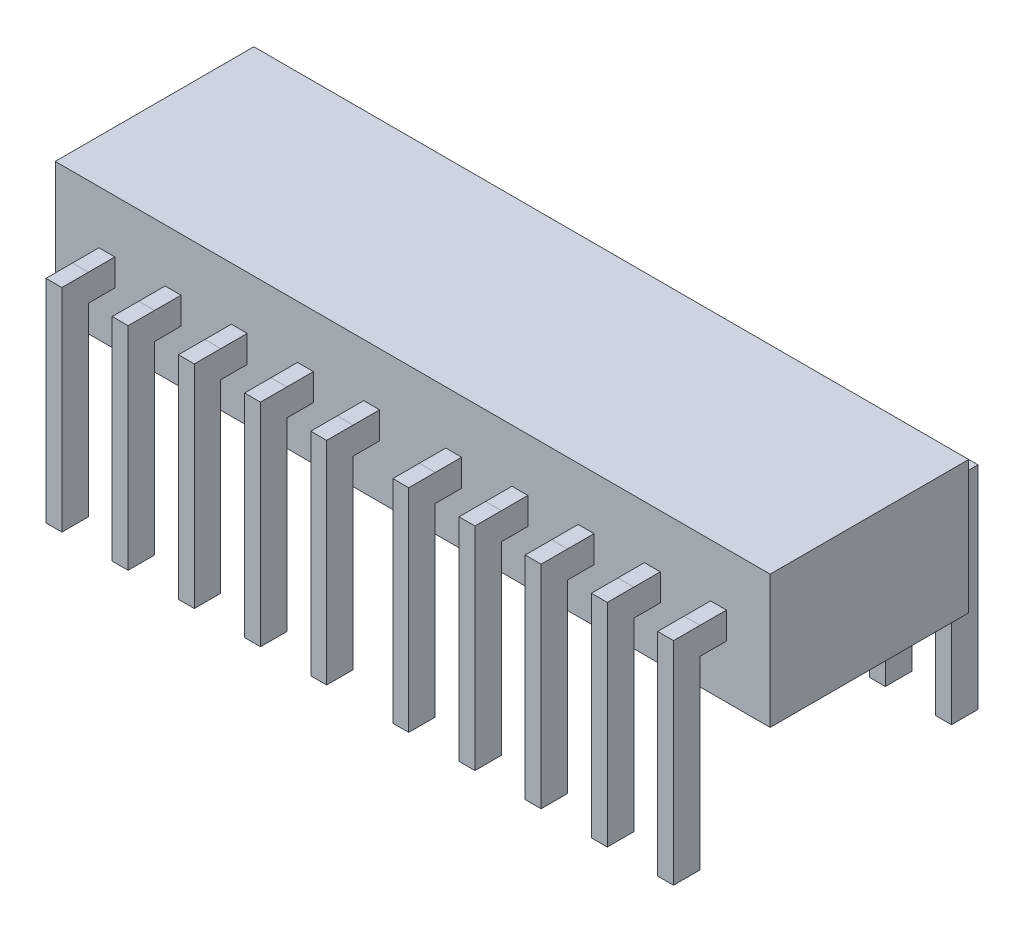
from build123d import *

# Parameters (mm, degrees)
BOSS_EXTRUDE3_DEPTH         = 2507.5
BOSS_EXTRUDE6_DEPTH         = 508
BOSS_EXTRUDE6_DEPTH_BACK    = 7494
SKETCH1_14_W                = 600
SKETCH1_14_H                = 1000
BOSS_EXTRUDE6_2_DEPTH       = 508
BOSS_EXTRUDE6_2_DEPTH_BACK  = 7494
BOSS_EXTRUDE6_3_DEPTH       = 508
BOSS_EXTRUDE6_3_DEPTH_BACK  = 7494
BOSS_EXTRUDE6_4_DEPTH       = 508
BOSS_EXTRUDE6_4_DEPTH_BACK  = 7494
BOSS_EXTRUDE6_5_DEPTH       = 508
BOSS_EXTRUDE6_5_DEPTH_BACK  = 7494
BOSS_EXTRUDE6_6_DEPTH       = 508
BOSS_EXTRUDE6_6_DEPTH_BACK  = 7494
BOSS_EXTRUDE6_7_DEPTH       = 508
BOSS_EXTRUDE6_7_DEPTH_BACK  = 7494
BOSS_EXTRUDE6_8_DEPTH       = 508
BOSS_EXTRUDE6_8_DEPTH_BACK  = 7494
BOSS_EXTRUDE6_9_DEPTH       = 508
BOSS_EXTRUDE6_9_DEPTH_BACK  = 7494
BOSS_EXTRUDE6_10_DEPTH      = 508
BOSS_EXTRUDE6_10_DEPTH_BACK = 7494
BOSS_EXTRUDE6_11_DEPTH      = 508
BOSS_EXTRUDE6_11_DEPTH_BACK = 7494
BOSS_EXTRUDE6_12_DEPTH      = 508
BOSS_EXTRUDE6_12_DEPTH_BACK = 7494
BOSS_EXTRUDE6_13_DEPTH      = 508
BOSS_EXTRUDE6_13_DEPTH_BACK = 7494
BOSS_EXTRUDE6_14_DEPTH      = 508
BOSS_EXTRUDE6_14_DEPTH_BACK = 7494
BOSS_EXTRUDE6_15_DEPTH      = 508
BOSS_EXTRUDE6_15_DEPTH_BACK = 7494
BOSS_EXTRUDE6_16_DEPTH      = 508
BOSS_EXTRUDE6_16_DEPTH_BACK = 7494
BOSS_EXTRUDE6_17_DEPTH      = 508
BOSS_EXTRUDE6_17_DEPTH_BACK = 7494
BOSS_EXTRUDE6_18_DEPTH      = 508
BOSS_EXTRUDE6_18_DEPTH_BACK = 7494
BOSS_EXTRUDE6_19_DEPTH      = 508
BOSS_EXTRUDE6_19_DEPTH_BACK = 7494
BOSS_EXTRUDE6_20_DEPTH      = 508
BOSS_EXTRUDE6_20_DEPTH_BACK = 7494
SKETCH1_17_W                = 600
SKETCH1_17_H                = 1000
BOSS_EXTRUDE8_DEPTH         = 507.5


with BuildPart() as part:
    # Sketch1 → Boss-Extrude3 (new, symmetric)
    with BuildSketch(Plane(origin=(0, 0, 0), x_dir=(1, 0, 0), z_dir=(0, 1, 0))):
        Polygon((-13500, 3750), (-13500, -3750), (-11850, -3750), (-11250, -3750), (-9350, -3750), (-8750, -3750), (-6850, -3750), (-6250, -3750), (-4350, -3750), (-3750, -3750), (-1850, -3750), (-1250, -3750), (1250, -3750), (1850, -3750), (3750, -3750), (4350, -3750), (6250, -3750), (6850, -3750), (8750, -3750), (9350, -3750), (11250, -3750), (11850, -3750), (13500, -3750), (13500, 3750), (11850, 3750), (11250, 3750), (9350, 3750), (8750, 3750), (6850, 3750), (6250, 3750), (4350, 3750), (3750, 3750), (1850, 3750), (1250, 3750), (-1250, 3750), (-1850, 3750), (-3750, 3750), (-4350, 3750), (-6250, 3750), (-6850, 3750), (-8750, 3750), (-9350, 3750), (-11250, 3750), (-11850, 3750), align=None)
    extrude(amount=BOSS_EXTRUDE3_DEPTH, both=True)



with BuildPart() as body_2:
    # Sketch1_14 → Boss-Extrude6 (new, two sides: drawn at the far end of the back side and taken through both)
    with BuildSketch(Plane(origin=(0, 0, 0), x_dir=(1, 0, 0), z_dir=(0, 1, 0)).offset(-BOSS_EXTRUDE6_DEPTH_BACK)):
        with Locations((-11550, -5250)):
            Rectangle(SKETCH1_14_W, SKETCH1_14_H)
    extrude(amount=BOSS_EXTRUDE6_DEPTH + BOSS_EXTRUDE6_DEPTH_BACK)


with BuildPart() as body_3:
    # Sketch1_14 → Boss-Extrude6 2 (new, two sides: drawn at the far end of the back side and taken through both)
    with BuildSketch(Plane(origin=(0, 0, 0), x_dir=(1, 0, 0), z_dir=(0, 1, 0)).offset(-BOSS_EXTRUDE6_2_DEPTH_BACK)):
        with Locations((-11550, 5250)):
            Rectangle(SKETCH1_14_W, SKETCH1_14_H)
    extrude(amount=BOSS_EXTRUDE6_2_DEPTH + BOSS_EXTRUDE6_2_DEPTH_BACK)


with BuildPart() as body_4:
    # Sketch1_14 → Boss-Extrude6 3 (new, two sides: drawn at the far end of the back side and taken through both)
    with BuildSketch(Plane(origin=(0, 0, 0), x_dir=(1, 0, 0), z_dir=(0, 1, 0)).offset(-BOSS_EXTRUDE6_3_DEPTH_BACK)):
        with Locations((-9050, -5250)):
            Rectangle(SKETCH1_14_W, SKETCH1_14_H)
    extrude(amount=BOSS_EXTRUDE6_3_DEPTH + BOSS_EXTRUDE6_3_DEPTH_BACK)


with BuildPart() as body_5:
    # Sketch1_14 → Boss-Extrude6 4 (new, two sides: drawn at the far end of the back side and taken through both)
    with BuildSketch(Plane(origin=(0, 0, 0), x_dir=(1, 0, 0), z_dir=(0, 1, 0)).offset(-BOSS_EXTRUDE6_4_DEPTH_BACK)):
        with Locations((-9050, 5250)):
            Rectangle(SKETCH1_14_W, SKETCH1_14_H)
    extrude(amount=BOSS_EXTRUDE6_4_DEPTH + BOSS_EXTRUDE6_4_DEPTH_BACK)


with BuildPart() as body_6:
    # Sketch1_14 → Boss-Extrude6 5 (new, two sides: drawn at the far end of the back side and taken through both)
    with BuildSketch(Plane(origin=(0, 0, 0), x_dir=(1, 0, 0), z_dir=(0, 1, 0)).offset(-BOSS_EXTRUDE6_5_DEPTH_BACK)):
        with Locations((-6550, -5250)):
            Rectangle(SKETCH1_14_W, SKETCH1_14_H)
    extrude(amount=BOSS_EXTRUDE6_5_DEPTH + BOSS_EXTRUDE6_5_DEPTH_BACK)


with BuildPart() as body_7:
    # Sketch1_14 → Boss-Extrude6 6 (new, two sides: drawn at the far end of the back side and taken through both)
    with BuildSketch(Plane(origin=(0, 0, 0), x_dir=(1, 0, 0), z_dir=(0, 1, 0)).offset(-BOSS_EXTRUDE6_6_DEPTH_BACK)):
        with Locations((-6550, 5250)):
            Rectangle(SKETCH1_14_W, SKETCH1_14_H)
    extrude(amount=BOSS_EXTRUDE6_6_DEPTH + BOSS_EXTRUDE6_6_DEPTH_BACK)


with BuildPart() as body_8:
    # Sketch1_14 → Boss-Extrude6 7 (new, two sides: drawn at the far end of the back side and taken through both)
    with BuildSketch(Plane(origin=(0, 0, 0), x_dir=(1, 0, 0), z_dir=(0, 1, 0)).offset(-BOSS_EXTRUDE6_7_DEPTH_BACK)):
        with Locations((-4050, -5250)):
            Rectangle(SKETCH1_14_W, SKETCH1_14_H)
    extrude(amount=BOSS_EXTRUDE6_7_DEPTH + BOSS_EXTRUDE6_7_DEPTH_BACK)


with BuildPart() as body_9:
    # Sketch1_14 → Boss-Extrude6 8 (new, two sides: drawn at the far end of the back side and taken through both)
    with BuildSketch(Plane(origin=(0, 0, 0), x_dir=(1, 0, 0), z_dir=(0, 1, 0)).offset(-BOSS_EXTRUDE6_8_DEPTH_BACK)):
        with Locations((-4050, 5250)):
            Rectangle(SKETCH1_14_W, SKETCH1_14_H)
    extrude(amount=BOSS_EXTRUDE6_8_DEPTH + BOSS_EXTRUDE6_8_DEPTH_BACK)


with BuildPart() as body_10:
    # Sketch1_14 → Boss-Extrude6 9 (new, two sides: drawn at the far end of the back side and taken through both)
    with BuildSketch(Plane(origin=(0, 0, 0), x_dir=(1, 0, 0), z_dir=(0, 1, 0)).offset(-BOSS_EXTRUDE6_9_DEPTH_BACK)):
        with Locations((-1550, -5250)):
            Rectangle(SKETCH1_14_W, SKETCH1_14_H)
    extrude(amount=BOSS_EXTRUDE6_9_DEPTH + BOSS_EXTRUDE6_9_DEPTH_BACK)


with BuildPart() as body_11:
    # Sketch1_14 → Boss-Extrude6 10 (new, two sides: drawn at the far end of the back side and taken through both)
    with BuildSketch(Plane(origin=(0, 0, 0), x_dir=(1, 0, 0), z_dir=(0, 1, 0)).offset(-BOSS_EXTRUDE6_10_DEPTH_BACK)):
        with Locations((-1550, 5250)):
            Rectangle(SKETCH1_14_W, SKETCH1_14_H)
    extrude(amount=BOSS_EXTRUDE6_10_DEPTH + BOSS_EXTRUDE6_10_DEPTH_BACK)


with BuildPart() as body_12:
    # Sketch1_14 → Boss-Extrude6 11 (new, two sides: drawn at the far end of the back side and taken through both)
    with BuildSketch(Plane(origin=(0, 0, 0), x_dir=(1, 0, 0), z_dir=(0, 1, 0)).offset(-BOSS_EXTRUDE6_11_DEPTH_BACK)):
        with Locations((1550, -5250)):
            Rectangle(SKETCH1_14_W, SKETCH1_14_H)
    extrude(amount=BOSS_EXTRUDE6_11_DEPTH + BOSS_EXTRUDE6_11_DEPTH_BACK)


with BuildPart() as body_13:
    # Sketch1_14 → Boss-Extrude6 12 (new, two sides: drawn at the far end of the back side and taken through both)
    with BuildSketch(Plane(origin=(0, 0, 0), x_dir=(1, 0, 0), z_dir=(0, 1, 0)).offset(-BOSS_EXTRUDE6_12_DEPTH_BACK)):
        with Locations((1550, 5250)):
            Rectangle(SKETCH1_14_W, SKETCH1_14_H)
    extrude(amount=BOSS_EXTRUDE6_12_DEPTH + BOSS_EXTRUDE6_12_DEPTH_BACK)


with BuildPart() as body_14:
    # Sketch1_14 → Boss-Extrude6 13 (new, two sides: drawn at the far end of the back side and taken through both)
    with BuildSketch(Plane(origin=(0, 0, 0), x_dir=(1, 0, 0), z_dir=(0, 1, 0)).offset(-BOSS_EXTRUDE6_13_DEPTH_BACK)):
        with Locations((4050, -5250)):
            Rectangle(SKETCH1_14_W, SKETCH1_14_H)
    extrude(amount=BOSS_EXTRUDE6_13_DEPTH + BOSS_EXTRUDE6_13_DEPTH_BACK)


with BuildPart() as body_15:
    # Sketch1_14 → Boss-Extrude6 14 (new, two sides: drawn at the far end of the back side and taken through both)
    with BuildSketch(Plane(origin=(0, 0, 0), x_dir=(1, 0, 0), z_dir=(0, 1, 0)).offset(-BOSS_EXTRUDE6_14_DEPTH_BACK)):
        with Locations((4050, 5250)):
            Rectangle(SKETCH1_14_W, SKETCH1_14_H)
    extrude(amount=BOSS_EXTRUDE6_14_DEPTH + BOSS_EXTRUDE6_14_DEPTH_BACK)


with BuildPart() as body_16:
    # Sketch1_14 → Boss-Extrude6 15 (new, two sides: drawn at the far end of the back side and taken through both)
    with BuildSketch(Plane(origin=(0, 0, 0), x_dir=(1, 0, 0), z_dir=(0, 1, 0)).offset(-BOSS_EXTRUDE6_15_DEPTH_BACK)):
        with Locations((6550, -5250)):
            Rectangle(SKETCH1_14_W, SKETCH1_14_H)
    extrude(amount=BOSS_EXTRUDE6_15_DEPTH + BOSS_EXTRUDE6_15_DEPTH_BACK)


with BuildPart() as body_17:
    # Sketch1_14 → Boss-Extrude6 16 (new, two sides: drawn at the far end of the back side and taken through both)
    with BuildSketch(Plane(origin=(0, 0, 0), x_dir=(1, 0, 0), z_dir=(0, 1, 0)).offset(-BOSS_EXTRUDE6_16_DEPTH_BACK)):
        with Locations((6550, 5250)):
            Rectangle(SKETCH1_14_W, SKETCH1_14_H)
    extrude(amount=BOSS_EXTRUDE6_16_DEPTH + BOSS_EXTRUDE6_16_DEPTH_BACK)


with BuildPart() as body_18:
    # Sketch1_14 → Boss-Extrude6 17 (new, two sides: drawn at the far end of the back side and taken through both)
    with BuildSketch(Plane(origin=(0, 0, 0), x_dir=(1, 0, 0), z_dir=(0, 1, 0)).offset(-BOSS_EXTRUDE6_17_DEPTH_BACK)):
        with Locations((9050, -5250)):
            Rectangle(SKETCH1_14_W, SKETCH1_14_H)
    extrude(amount=BOSS_EXTRUDE6_17_DEPTH + BOSS_EXTRUDE6_17_DEPTH_BACK)


with BuildPart() as body_19:
    # Sketch1_14 → Boss-Extrude6 18 (new, two sides: drawn at the far end of the back side and taken through both)
    with BuildSketch(Plane(origin=(0, 0, 0), x_dir=(1, 0, 0), z_dir=(0, 1, 0)).offset(-BOSS_EXTRUDE6_18_DEPTH_BACK)):
        with Locations((9050, 5250)):
            Rectangle(SKETCH1_14_W, SKETCH1_14_H)
    extrude(amount=BOSS_EXTRUDE6_18_DEPTH + BOSS_EXTRUDE6_18_DEPTH_BACK)


with BuildPart() as body_20:
    # Sketch1_14 → Boss-Extrude6 19 (new, two sides: drawn at the far end of the back side and taken through both)
    with BuildSketch(Plane(origin=(0, 0, 0), x_dir=(1, 0, 0), z_dir=(0, 1, 0)).offset(-BOSS_EXTRUDE6_19_DEPTH_BACK)):
        with Locations((11550, -5250)):
            Rectangle(SKETCH1_14_W, SKETCH1_14_H)
    extrude(amount=BOSS_EXTRUDE6_19_DEPTH + BOSS_EXTRUDE6_19_DEPTH_BACK)


with BuildPart() as body_21:
    # Sketch1_14 → Boss-Extrude6 20 (new, two sides: drawn at the far end of the back side and taken through both)
    with BuildSketch(Plane(origin=(0, 0, 0), x_dir=(1, 0, 0), z_dir=(0, 1, 0)).offset(-BOSS_EXTRUDE6_20_DEPTH_BACK)):
        with Locations((11550, 5250)):
            Rectangle(SKETCH1_14_W, SKETCH1_14_H)
    extrude(amount=BOSS_EXTRUDE6_20_DEPTH + BOSS_EXTRUDE6_20_DEPTH_BACK)


with BuildPart() as part_1:
    add(part.part)

    add(body_2.part)  # Boss-Extrude8 merges body 2

    add(body_3.part)  # Boss-Extrude8 merges body 3

    add(body_4.part)  # Boss-Extrude8 merges body 4

    add(body_5.part)  # Boss-Extrude8 merges body 5

    add(body_6.part)  # Boss-Extrude8 merges body 6

    add(body_7.part)  # Boss-Extrude8 merges body 7

    add(body_8.part)  # Boss-Extrude8 merges body 8

    add(body_9.part)  # Boss-Extrude8 merges body 9

    add(body_10.part)  # Boss-Extrude8 merges body 10

    add(body_11.part)  # Boss-Extrude8 merges body 11

    add(body_12.part)  # Boss-Extrude8 merges body 12

    add(body_13.part)  # Boss-Extrude8 merges body 13

    add(body_14.part)  # Boss-Extrude8 merges body 14

    add(body_15.part)  # Boss-Extrude8 merges body 15

    add(body_16.part)  # Boss-Extrude8 merges body 16

    add(body_17.part)  # Boss-Extrude8 merges body 17

    add(body_18.part)  # Boss-Extrude8 merges body 18

    add(body_19.part)  # Boss-Extrude8 merges body 19

    add(body_20.part)  # Boss-Extrude8 merges body 20

    add(body_21.part)  # Boss-Extrude8 merges body 21
    # Sketch1_17 → Boss-Extrude8 (add, symmetric)
    with BuildSketch(Plane(origin=(0, 0, 0), x_dir=(1, 0, 0), z_dir=(0, 1, 0))):
        with Locations((-11550, -4250)):
            Rectangle(SKETCH1_17_W, SKETCH1_17_H)
        with Locations((-11550, 4250)):
            Rectangle(SKETCH1_17_W, SKETCH1_17_H)
        with Locations((-9050, -4250)):
            Rectangle(SKETCH1_17_W, SKETCH1_17_H)
        with Locations((-9050, 4250)):
            Rectangle(SKETCH1_17_W, SKETCH1_17_H)
        with Locations((-6550, -4250)):
            Rectangle(SKETCH1_17_W, SKETCH1_17_H)
        with Locations((-6550, 4250)):
            Rectangle(SKETCH1_17_W, SKETCH1_17_H)
        with Locations((-4050, -4250)):
            Rectangle(SKETCH1_17_W, SKETCH1_17_H)
        with Locations((-4050, 4250)):
            Rectangle(SKETCH1_17_W, SKETCH1_17_H)
        with Locations((-1550, -4250)):
            Rectangle(SKETCH1_17_W, SKETCH1_17_H)
        with Locations((-1550, 4250)):
            Rectangle(SKETCH1_17_W, SKETCH1_17_H)
        with Locations((1550, -4250)):
            Rectangle(SKETCH1_17_W, SKETCH1_17_H)
        with Locations((1550, 4250)):
            Rectangle(SKETCH1_17_W, SKETCH1_17_H)
        with Locations((4050, -4250)):
            Rectangle(SKETCH1_17_W, SKETCH1_17_H)
        with Locations((4050, 4250)):
            Rectangle(SKETCH1_17_W, SKETCH1_17_H)
        with Locations((6550, -4250)):
            Rectangle(SKETCH1_17_W, SKETCH1_17_H)
        with Locations((6550, 4250)):
            Rectangle(SKETCH1_17_W, SKETCH1_17_H)
        with Locations((9050, -4250)):
            Rectangle(SKETCH1_17_W, SKETCH1_17_H)
        with Locations((9050, 4250)):
            Rectangle(SKETCH1_17_W, SKETCH1_17_H)
        with Locations((11550, -4250)):
            Rectangle(SKETCH1_17_W, SKETCH1_17_H)
        with Locations((11550, 4250)):
            Rectangle(SKETCH1_17_W, SKETCH1_17_H)
    extrude(amount=BOSS_EXTRUDE8_DEPTH, both=True)


solid = part_1.part
